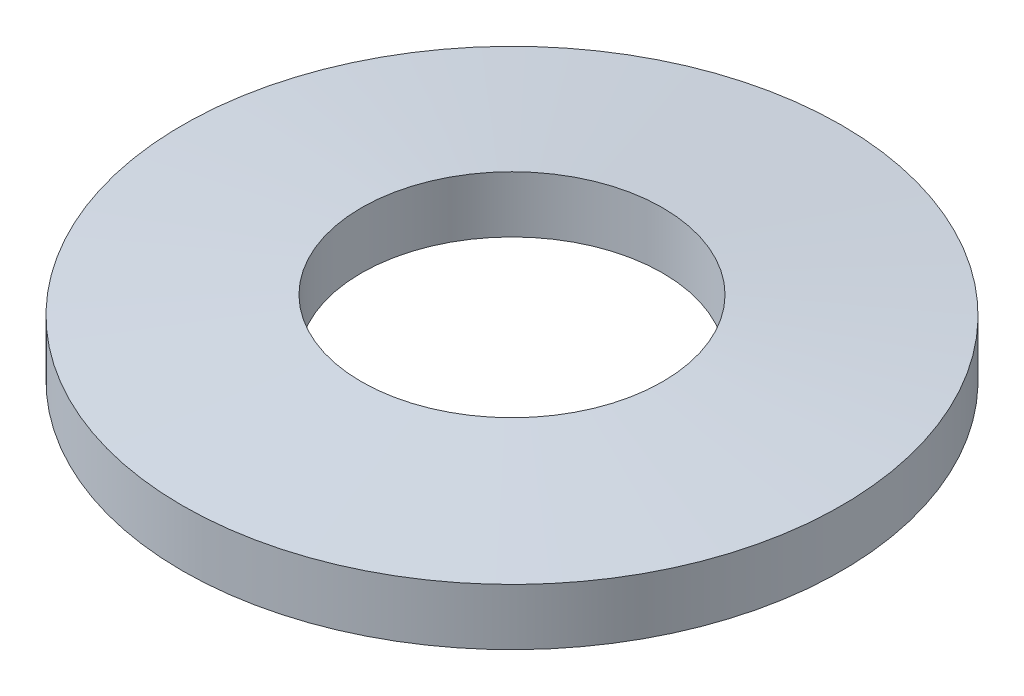
from build123d import *


with BuildPart() as part:
    # Sketch1 → Revolve1 (revolve)
    with BuildSketch(Plane.XY):
        Polygon((1.6, 0.79), (1.6, 0.19), (3.5, 0), (3.5, 0.6), align=None)
    revolve(axis=Axis((0, 0, 0), (0, 1, 0)))


solid = part.part
